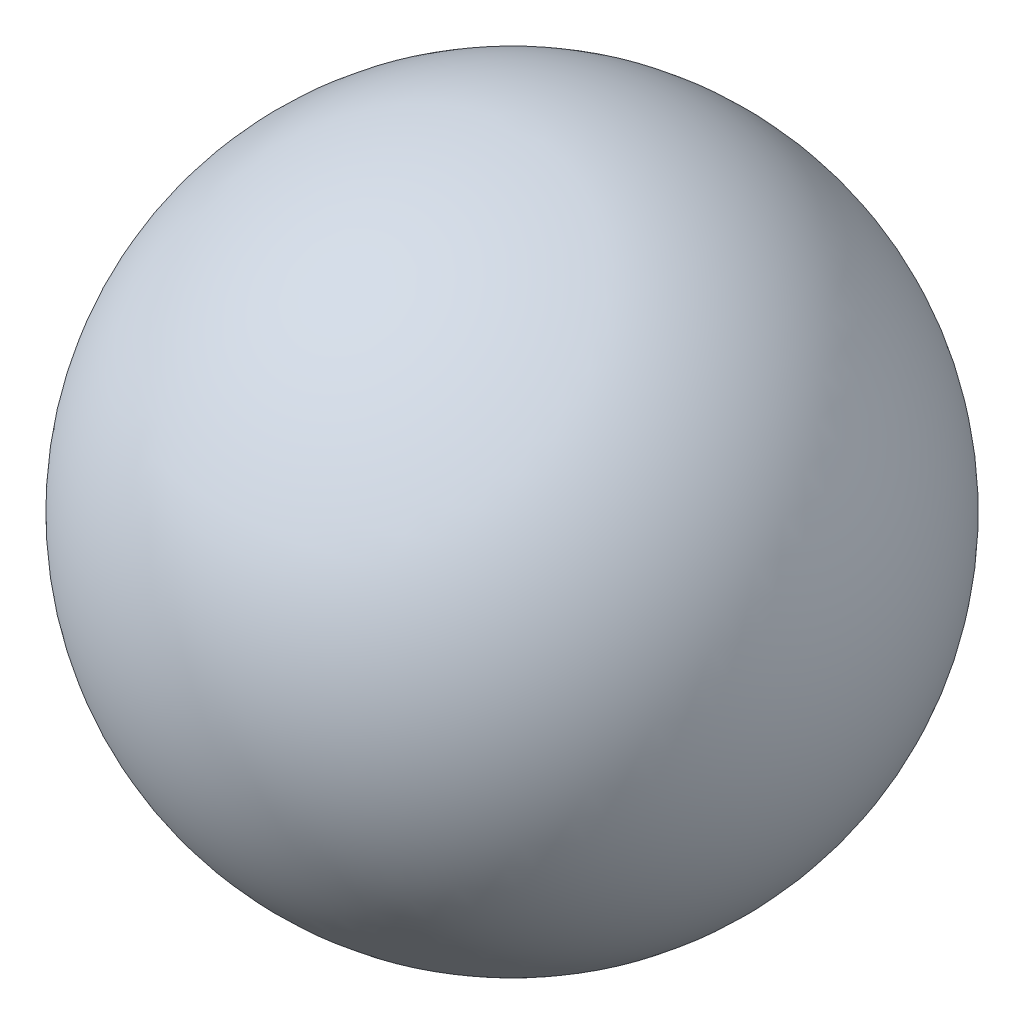
from build123d import *


with BuildPart() as part:
    # Sketch1 → Revolve1 (revolve)
    with BuildSketch(Plane.XY):
        with BuildLine():
            Line((0, 3.4326529), (0, -3.4326529))
            ThreePointArc((0, -3.4326529), (3.4326529, 0), (0, 3.4326529))
        make_face()
    revolve(axis=Axis((0, 3.4326529, 0), (0, -1, 0)))


solid = part.part
